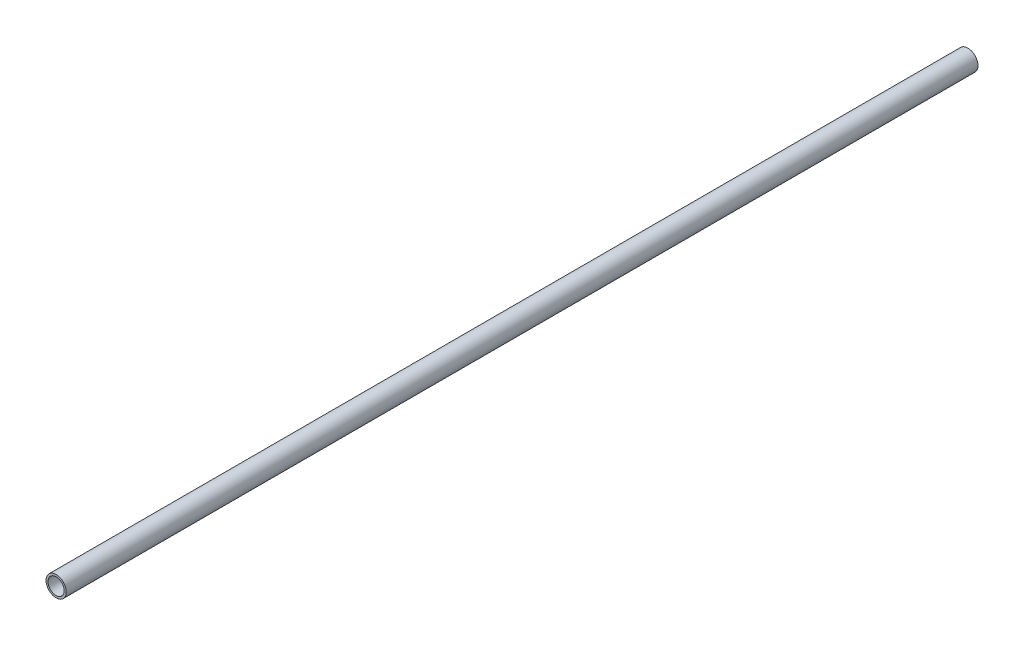
from build123d import *

# Parameters (mm, degrees)
SKETCH1_R           = 5
SKETCH1_R_2         = 4
BOSS_EXTRUDE1_DEPTH = 450


with BuildPart() as part:
    # Sketch1 → Boss-Extrude1 (new body)
    with BuildSketch(Plane.XY):
        Circle(SKETCH1_R)
        Circle(SKETCH1_R_2, mode=Mode.SUBTRACT)
    extrude(amount=BOSS_EXTRUDE1_DEPTH)


solid = part.part
